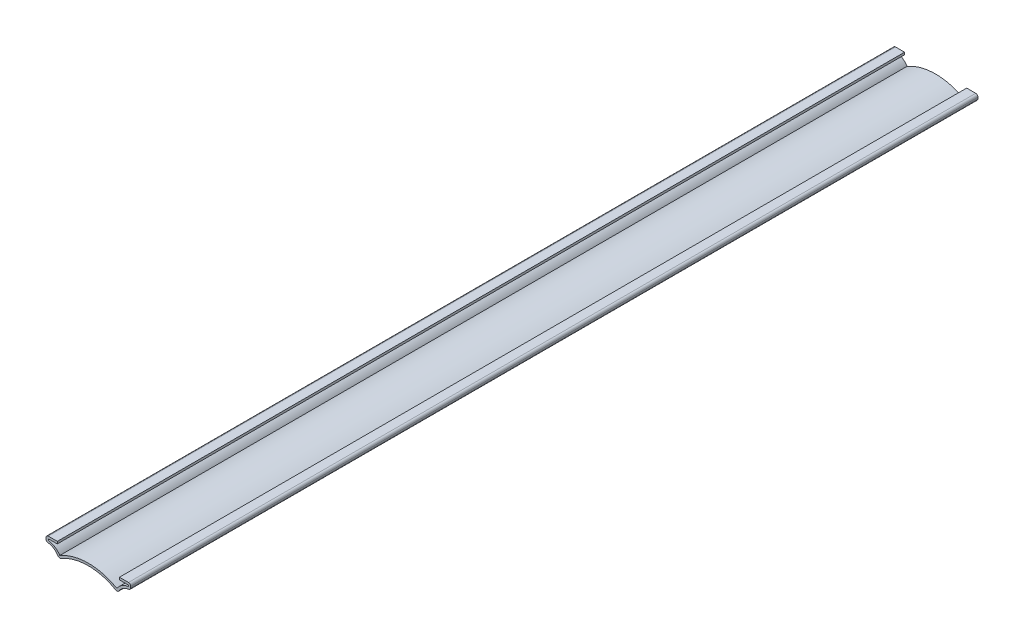
from build123d import *

# Parameters (mm, degrees)
EXTRUDE_THIN1_DEPTH = 476.25
FILLET1_R           = 1.27


with BuildPart() as part:
    # Sketch1 → Extrude-Thin1 (new body)
    with BuildSketch(Plane.XY):
        with BuildLine():
            Line((-17.4625, 0), (-23.8125, 0))
            Line((-23.8125, 0), (-23.8125, -3.175))
            ThreePointArc((-23.8125, -3.175), (-19.4649522, -4.471511039), (-16.537661084, -7.9375))
            ThreePointArc((-16.537661084, -7.9375), (-8.60836669, -4.370835686), (0, -3.149841478))
            Line((0, -3.149841478), (0, -1.879841478))
            ThreePointArc((0, -1.879841478), (-8.305471157, -2.968488199), (-16.049802005, -6.160876419))
            ThreePointArc((-16.049802005, -6.160876419), (-18.838548597, -3.364089602), (-22.5425, -1.993006799))
            Line((-22.5425, -1.993006799), (-22.5425, -1.27))
            Line((-22.5425, -1.27), (-17.4625, -1.27))
            Line((-17.4625, -1.27), (-17.4625, 0))
        make_face()
    extrude(amount=-EXTRUDE_THIN1_DEPTH)

    # Mirror1: part across plane


with BuildPart() as part_1:
    add(part.part)
    add(part.part.mirror(Plane(origin=(0, -1.879841478, -476.25), x_dir=(0, 0, 1), z_dir=(-1, 0, 0))))

    # Fillet1
    fillet1_edges = [part_1.edges().sort_by_distance(p)[0] for p in [
        (-16.537661084, -7.9375, -238.125),
        (-23.8125, -3.175, -238.125),
        (-23.8125, 0, -238.125),
        (16.537661084, -7.9375, -238.125),
        (23.8125, -3.175, -238.125),
        (23.8125, 0, -238.125),
    ]]
    fillet(fillet1_edges, radius=FILLET1_R)


solid = part_1.part
